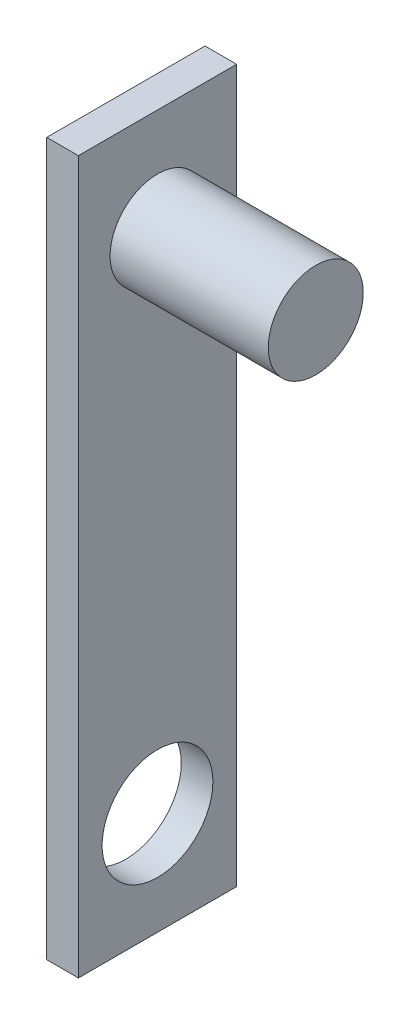
from build123d import *

# Parameters (mm, degrees)
SKETCH1_W           = 10
SKETCH1_H           = 45
BOSS_EXTRUDE1_DEPTH = 2
SKETCH2_R           = 3.5
CUT_EXTRUDE1_DEPTH  = 2
SKETCH3_R           = 3
BOSS_EXTRUDE2_DEPTH = 10


with BuildPart() as part:
    # Sketch1 → Boss-Extrude1 (new body)
    with BuildSketch(Plane(origin=(0, 0, 0), x_dir=(0, 0, -1), z_dir=(1, 0, 0))):
        Rectangle(SKETCH1_W, SKETCH1_H)
    extrude(amount=BOSS_EXTRUDE1_DEPTH)

    # Sketch2 → Cut-Extrude1 (cut)
    with BuildSketch(Plane(origin=(2, 0, 0), x_dir=(0, 0, -1), z_dir=(1, 0, 0))):
        with Locations((0, -16)):
            Circle(SKETCH2_R)
    extrude(amount=-CUT_EXTRUDE1_DEPTH, mode=Mode.SUBTRACT)

    # Sketch3 → Boss-Extrude2 (add)
    with BuildSketch(Plane(origin=(2, 0, 0), x_dir=(0, 0, -1), z_dir=(1, 0, 0))):
        with Locations((0, 16)):
            Circle(SKETCH3_R)
    extrude(amount=BOSS_EXTRUDE2_DEPTH)


solid = part.part
